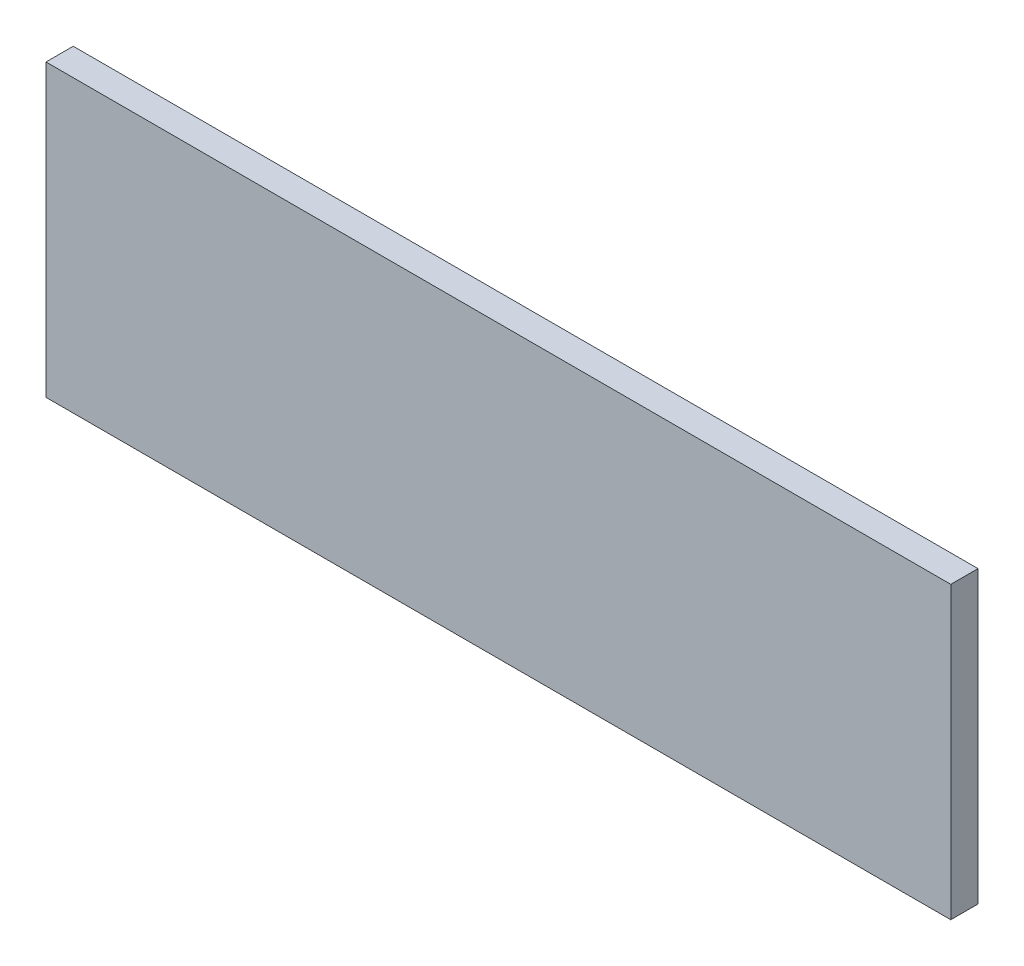
from build123d import *

# Parameters (mm, degrees)
SKETCH1_W           = 598
SKETCH1_H           = 192
BOSS_EXTRUDE1_DEPTH = 18


with BuildPart() as part:
    # Sketch1 → Boss-Extrude1 (new body)
    with BuildSketch(Plane.XY):
        Rectangle(SKETCH1_W, SKETCH1_H)
    extrude(amount=BOSS_EXTRUDE1_DEPTH)


solid = part.part
